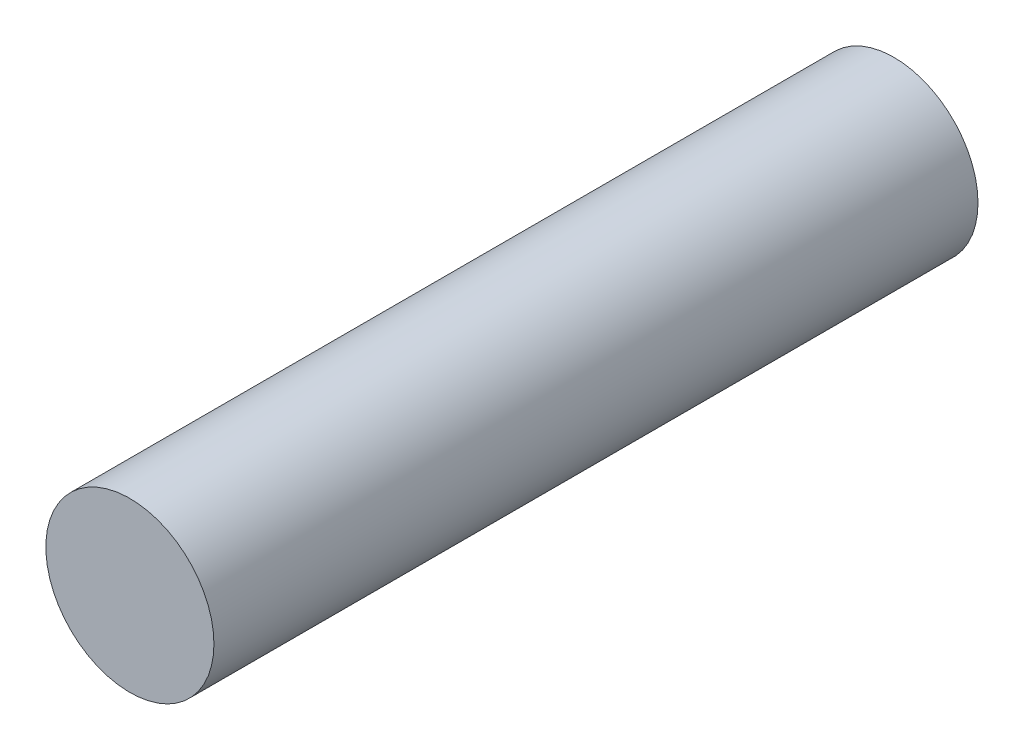
from build123d import *

# Parameters (mm, degrees)
SZKIC1_R                    = 5.5
DODANIE_WYCI_GNI_CIE1_DEPTH = 50


with BuildPart() as part:
    # Szkic1 → Dodanie-wyciągnięcie1 (new body)
    with BuildSketch(Plane.XY):
        Circle(SZKIC1_R)
    extrude(amount=DODANIE_WYCI_GNI_CIE1_DEPTH)


solid = part.part
